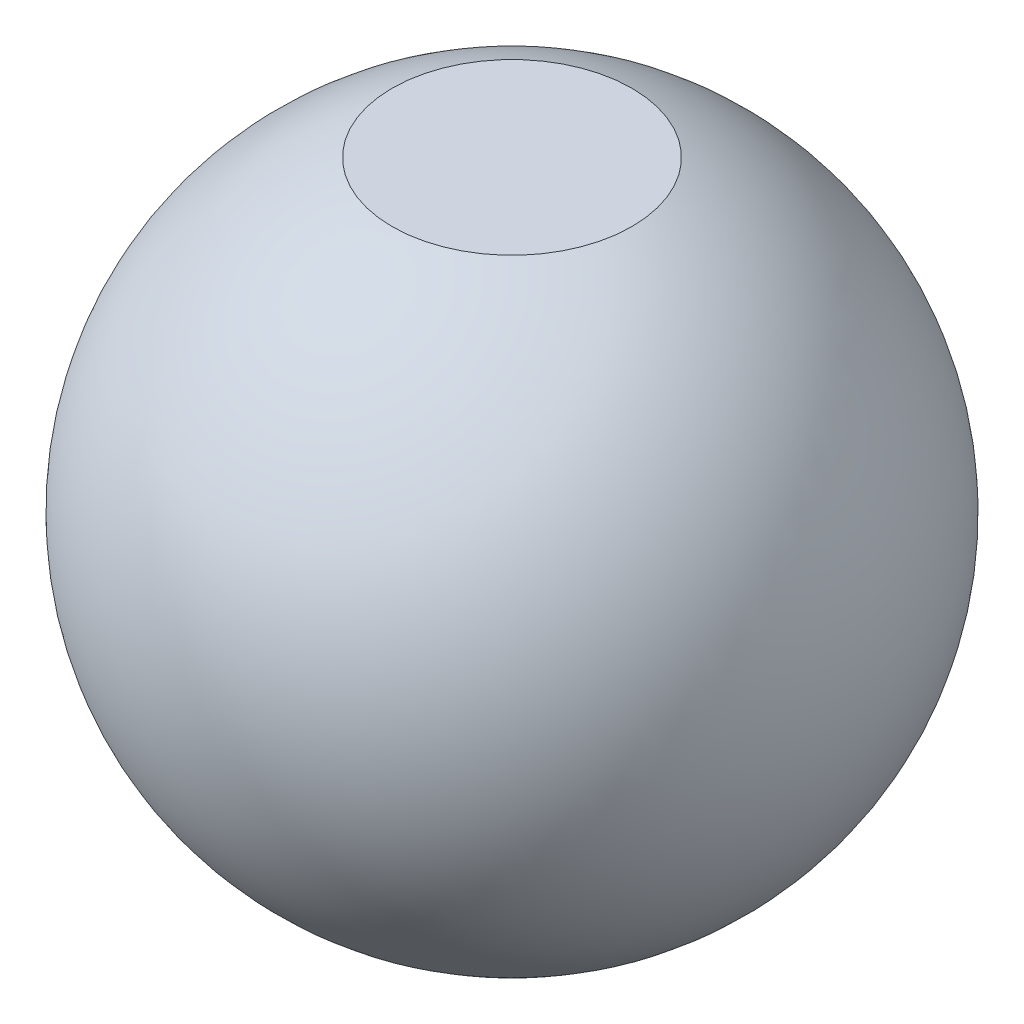
from build123d import *


with BuildPart() as part:
    # Sketch1 → Revolve1 (revolve)
    with BuildSketch(Plane.XY):
        with BuildLine():
            Line((19.999369365, 51.235), (0, 51.235))
            Line((0, 51.235), (0, -51.235))
            Line((0, -51.235), (19.999369365, -51.235))
            ThreePointArc((19.999369365, -51.235), (55, 0), (19.999369365, 51.235))
        make_face()
    revolve(axis=Axis((0, 51.235, 0), (0, -1, 0)))


solid = part.part
